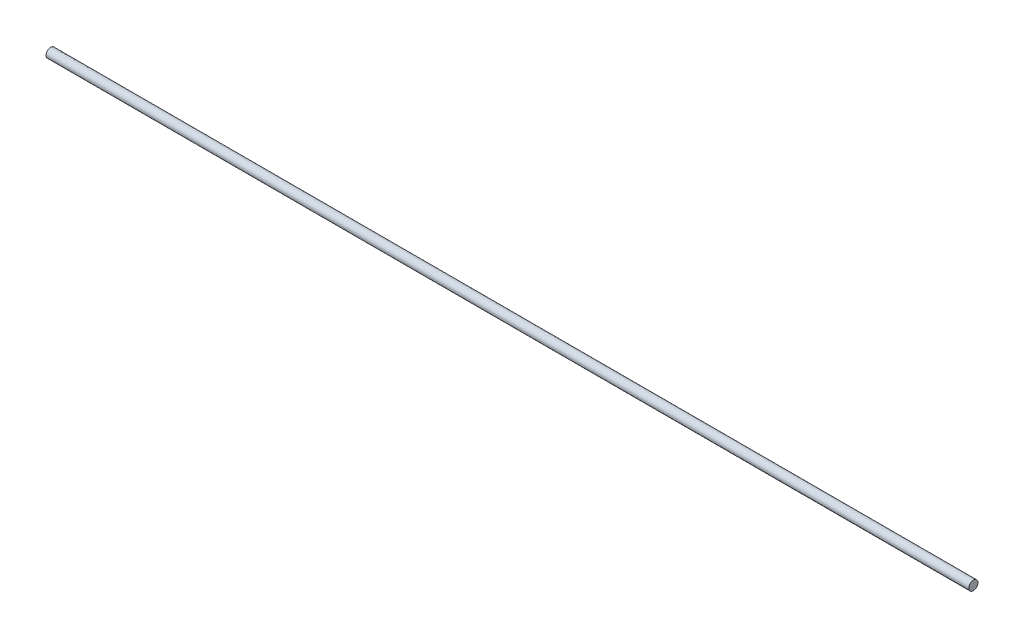
from build123d import *

# Parameters (mm, degrees)
SKETCH_1_R      = 0.5
EXTRUDE_1_DEPTH = 100


with BuildPart() as part:
    # 草图1 → 凸台-拉伸1 (new body)
    with BuildSketch(Plane(origin=(0, 0, 0), x_dir=(0, 0, -1), z_dir=(1, 0, 0))):
        Circle(SKETCH_1_R)
    extrude(amount=EXTRUDE_1_DEPTH)


solid = part.part
